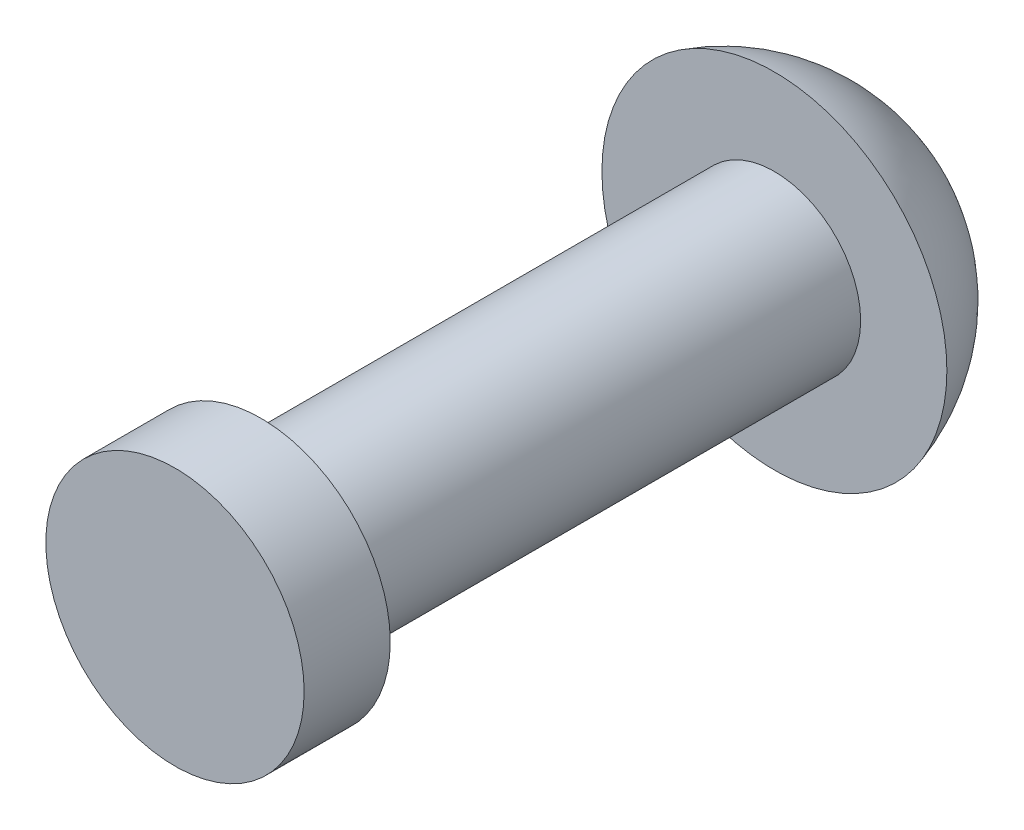
from build123d import *

# Parameters (mm, degrees)
SKETCH1_R        = 1.984375
EXT_SHANK_DEPTH  = 13.7922
SKETCH3_R        = 2.9718
EXT_CLINCH_DEPTH = 1.9812


with BuildPart() as part:
    # Sketch1 → Ext Shank (new body)
    with BuildSketch(Plane.XY):
        Circle(SKETCH1_R)
    extrude(amount=EXT_SHANK_DEPTH)

    # Sketch2 → Rev Head (revolve)
    with BuildSketch(Plane(origin=(0, 0, 0), x_dir=(1, 0, 0), z_dir=(0, 1, 0))):
        with BuildLine():
            Line((0, 2.9718), (0, 0))
            Line((0, 0), (3.96875, 0))
            ThreePointArc((3.96875, 0), (2.479040732, 2.146511287), (0, 2.9718))
        make_face()
    revolve(axis=Axis((0, 0, 0), (0, 0, -1)))

    # Sketch3 → Ext Clinch (add)
    with BuildSketch(Plane.XY.offset(13.7922)):
        Circle(SKETCH3_R)
    extrude(amount=-EXT_CLINCH_DEPTH)


solid = part.part
